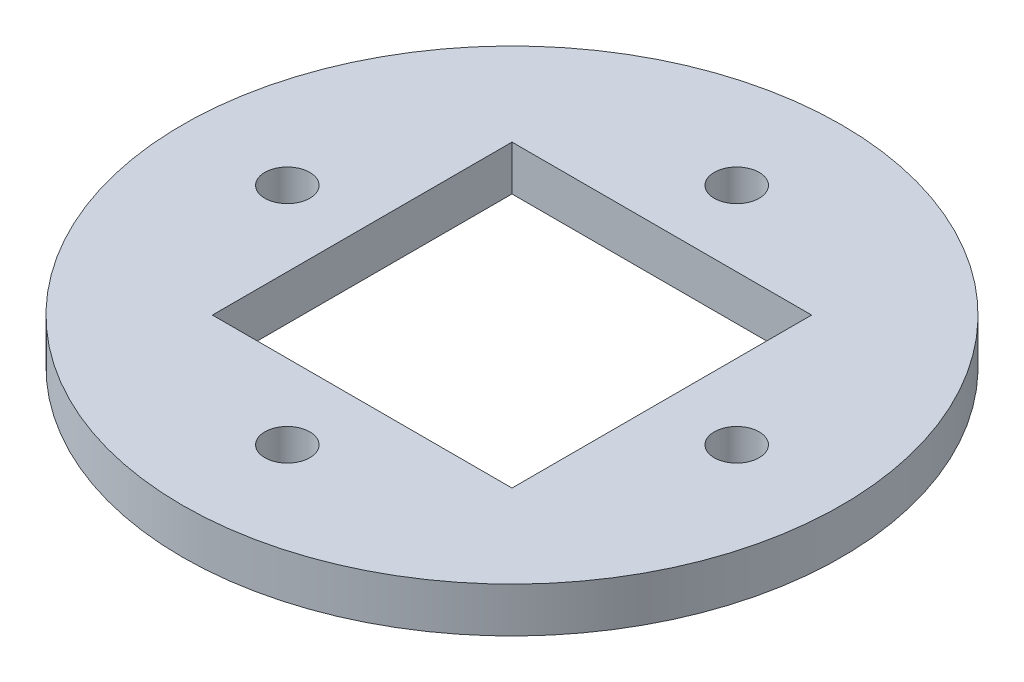
from build123d import *

# Parameters (mm, degrees)
SKETCH1_R           = 22
SKETCH1_R_2         = 1.5
SKETCH1_W           = 20
SKETCH1_H           = 20
BOSS_EXTRUDE1_DEPTH = 3


with BuildPart() as part:
    # Sketch1 → Boss-Extrude1 (new body)
    with BuildSketch(Plane(origin=(0, 0, 0), x_dir=(1, 0, 0), z_dir=(0, 1, 0))):
        Circle(SKETCH1_R)
        with Locations((-15, 0)):
            Circle(SKETCH1_R_2, mode=Mode.SUBTRACT)
        with Locations((0, 15)):
            Circle(SKETCH1_R_2, mode=Mode.SUBTRACT)
        with Locations((15, 0)):
            Circle(SKETCH1_R_2, mode=Mode.SUBTRACT)
        with Locations((0, -15)):
            Circle(SKETCH1_R_2, mode=Mode.SUBTRACT)
        Rectangle(SKETCH1_W, SKETCH1_H, mode=Mode.SUBTRACT)
    extrude(amount=BOSS_EXTRUDE1_DEPTH)


solid = part.part
